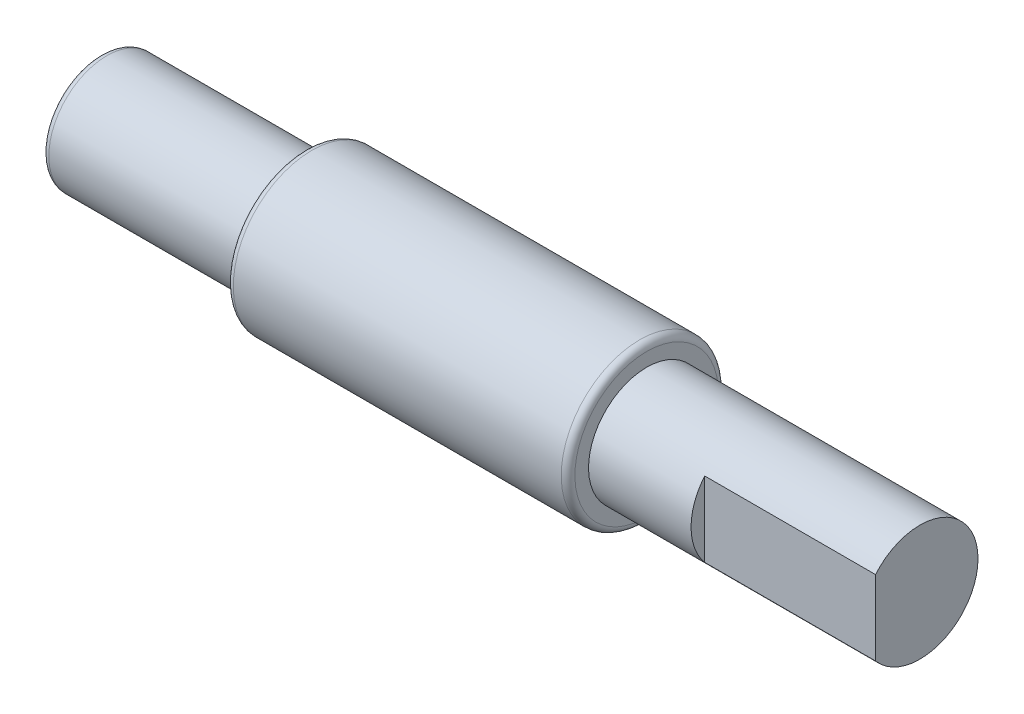
from build123d import *

# Parameters (mm, degrees)
ENL_V_MAT_EXTRU_6_DEPTH = 25


with BuildPart() as part:
    # Esquisse1 → Révolution1 (revolve)
    with BuildSketch(Plane.XY):
        with BuildLine():
            Line((0, 0), (-120, 0))
            Line((-120, 0), (-120, 7.5))
            ThreePointArc((-120, 7.5), (-119.707106781, 8.207106781), (-119, 8.5))
            Line((-119, 8.5), (-90, 8.5))
            Line((-90, 8.5), (-90, 10.5))
            ThreePointArc((-90, 10.5), (-89.707106781, 11.207106781), (-89, 11.5))
            Line((-89, 11.5), (-41, 11.5))
            ThreePointArc((-41, 11.5), (-40.292893219, 11.207106781), (-40, 10.5))
            Line((-40, 10.5), (-40, 8.5))
            Line((-40, 8.5), (0, 8.5))
            Line((0, 8.5), (0, 0))
        make_face()
    revolve(axis=Axis((0, 0, 0), (-1, 0, 0)))

    # Esquisse6 → Enlèv. mat.-Extru.6 (cut)
    with BuildSketch(Plane(origin=(0, 0, 0), x_dir=(0, 0, -1), z_dir=(1, 0, 0))):
        Polygon((-6.5, 9.404987847), (-6.5, -10.595012153), (-12.325260954, -10.595012153), (-12.325260954, 19.404987847), (-6.5, 19.404987847), align=None)
    extrude(amount=-ENL_V_MAT_EXTRU_6_DEPTH, mode=Mode.SUBTRACT)


solid = part.part
